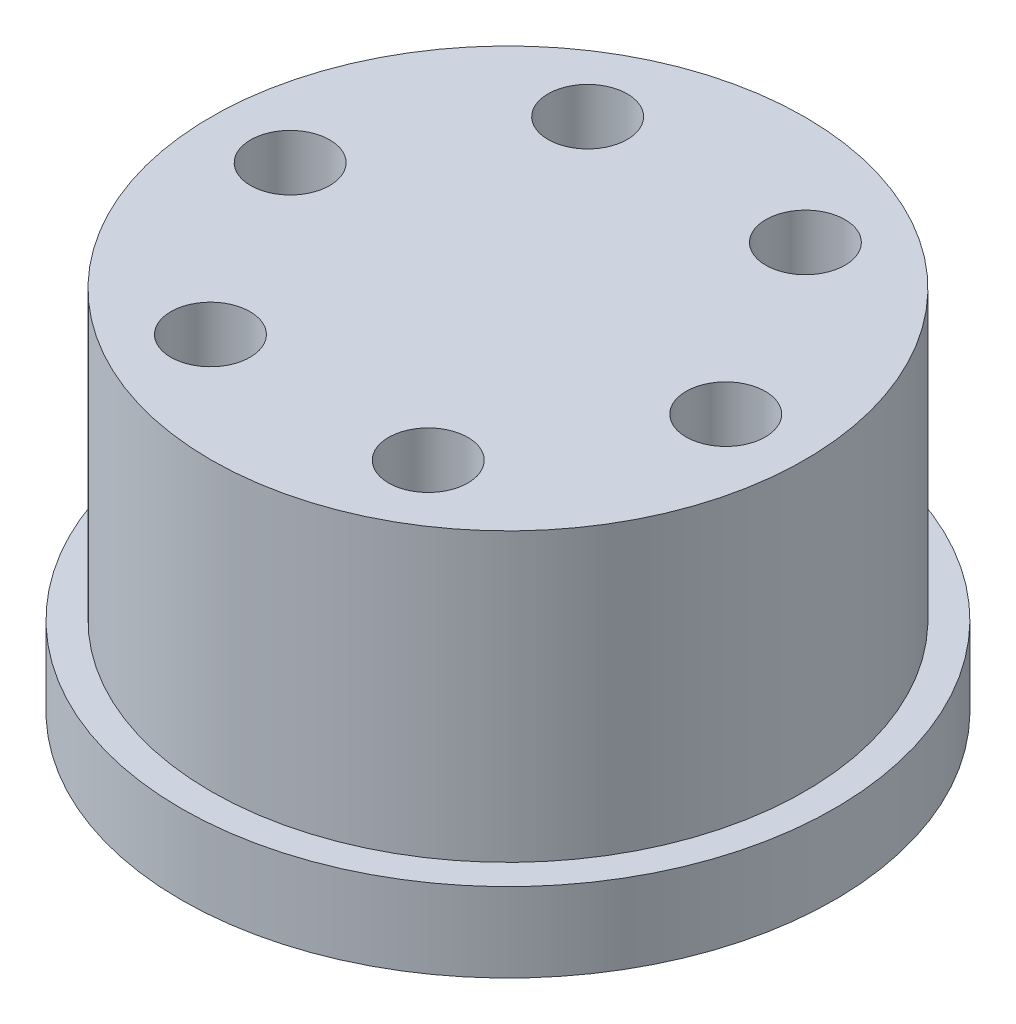
from build123d import *

# Parameters (mm, degrees)
SKETCH1_R           = 16.5
SKETCH1_R_2         = 1.65
BOSS_EXTRUDE1_DEPTH = 4
SKETCH2_R           = 15
BOSS_EXTRUDE2_DEPTH = 14.5
SKETCH5_R           = 2
CUT_EXTRUDE3_DEPTH  = 6.5
SKETCH6_R           = 7.6
CUT_EXTRUDE4_DEPTH  = 5


with BuildPart() as part:
    # Sketch1 → Boss-Extrude1 (new body)
    with BuildSketch(Plane(origin=(0, 0, 0), x_dir=(1, 0, 0), z_dir=(0, 1, 0))):
        Circle(SKETCH1_R)
        with Locations((0, 12.5)):
            Circle(SKETCH1_R_2, mode=Mode.SUBTRACT)
        with Locations((10.825317547, 6.25)):
            Circle(SKETCH1_R_2, mode=Mode.SUBTRACT)
        with Locations((10.825317547, -6.25)):
            Circle(SKETCH1_R_2, mode=Mode.SUBTRACT)
        with Locations((0, -12.5)):
            Circle(SKETCH1_R_2, mode=Mode.SUBTRACT)
        with Locations((-10.825317547, -6.25)):
            Circle(SKETCH1_R_2, mode=Mode.SUBTRACT)
        with Locations((-10.825317547, 6.25)):
            Circle(SKETCH1_R_2, mode=Mode.SUBTRACT)
    extrude(amount=BOSS_EXTRUDE1_DEPTH)

    # Sketch2 → Boss-Extrude2 (add)
    with BuildSketch(Plane(origin=(0, 4, 0), x_dir=(1, 0, 0), z_dir=(0, 1, 0))):
        Circle(SKETCH2_R)
    extrude(amount=BOSS_EXTRUDE2_DEPTH)

    # Sketch5 → Cut-Extrude3 (cut)
    with BuildSketch(Plane(origin=(0, 18.5, 0), x_dir=(1, 0, 0), z_dir=(0, 1, 0))):
        with Locations((-11, 0)):
            Circle(SKETCH5_R)
        with Locations((-5.5, 9.526279442)):
            Circle(SKETCH5_R)
        with Locations((5.5, 9.526279442)):
            Circle(SKETCH5_R)
        with Locations((11, 0)):
            Circle(SKETCH5_R)
        with Locations((5.5, -9.526279442)):
            Circle(SKETCH5_R)
        with Locations((-5.5, -9.526279442)):
            Circle(SKETCH5_R)
    extrude(amount=-CUT_EXTRUDE3_DEPTH, mode=Mode.SUBTRACT)

    # Sketch6 → Cut-Extrude4 (cut)
    with BuildSketch(Plane.XZ):
        Circle(SKETCH6_R)
    extrude(amount=-CUT_EXTRUDE4_DEPTH, mode=Mode.SUBTRACT)


solid = part.part
